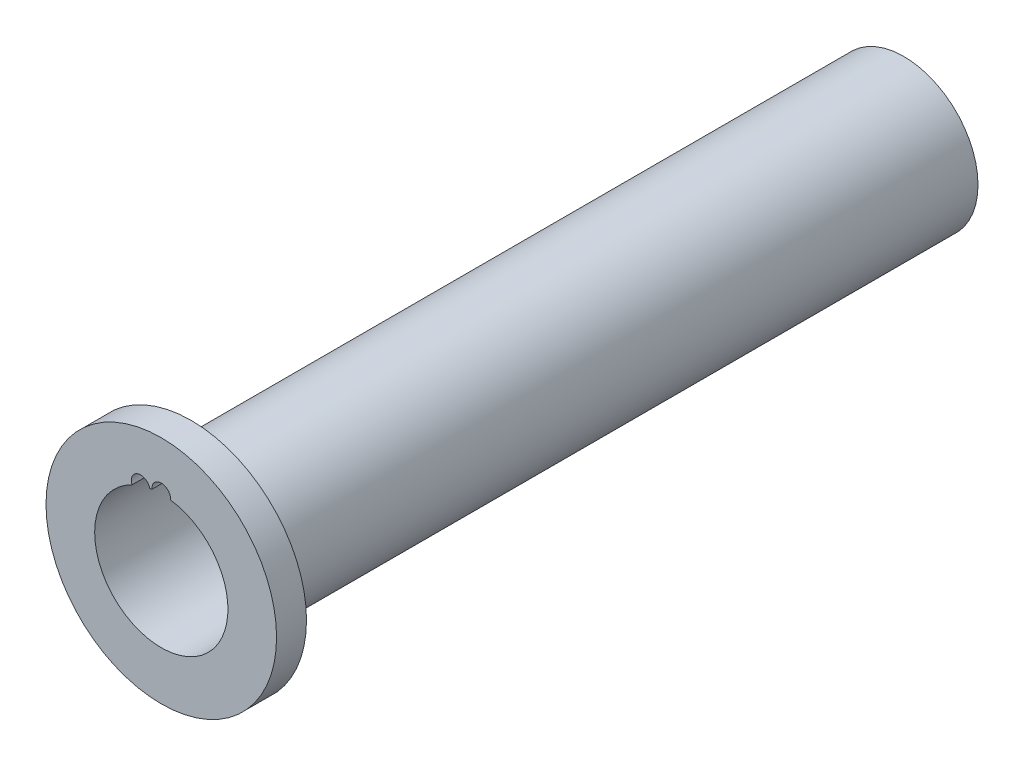
from build123d import *

# Parameters (mm, degrees)
SKETCH1_R                      = 4.95
SKETCH1_R_2                    = 4.45
BOSS_EXTRUDE1_DEPTH            = 47.6
SKETCH5_R                      = 7.7
SKETCH5_R_2                    = 4.45
BOSS_EXTRUDE3_DEPTH            = 2
SKETCH2_R                      = 0.625
CUT_EXTRUDE1_DEPTH             = 0.7
CUT_EXTRUDE1_DIRECTION_2_REACH = 4


with BuildPart() as part:
    # Sketch1 → Boss-Extrude1 (new body)
    with BuildSketch(Plane.XY):
        Circle(SKETCH1_R)
        Circle(SKETCH1_R_2, mode=Mode.SUBTRACT)
    extrude(amount=BOSS_EXTRUDE1_DEPTH)

    # Sketch5 → Boss-Extrude3 (add)
    with BuildSketch(Plane.XY.offset(47.6)):
        Circle(SKETCH5_R)
        Circle(SKETCH5_R_2, mode=Mode.SUBTRACT)
    extrude(amount=BOSS_EXTRUDE3_DEPTH)

    # Sketch2 → Cut-Extrude1 (cut)
    with BuildSketch(Plane(origin=(0, 0, 47.6), x_dir=(-1, 0, 0), z_dir=(0, 0, -1))):
        with Locations((0, 4.45)):
            Circle(SKETCH2_R)
        with Locations((1.375125625, 4.232201498)):
            Circle(SKETCH2_R)
    extrude(amount=CUT_EXTRUDE1_DEPTH, mode=Mode.SUBTRACT)

    # Sketch2 → Cut-Extrude1 direction 2 (cut, up to next)
    with BuildSketch(Plane(origin=(0, 0, 47.6), x_dir=(-1, 0, 0), z_dir=(0, 0, -1)), mode=Mode.PRIVATE) as cut_extrude1_direction_2_sk1:
        with Locations((0, 4.45)):
            Circle(SKETCH2_R)
    cut_extrude1_direction_2_tool1 = extrude(cut_extrude1_direction_2_sk1.sketch, amount=-CUT_EXTRUDE1_DIRECTION_2_REACH, mode=Mode.PRIVATE) & part.part
    add(cut_extrude1_direction_2_tool1.solids().sort_by_distance((0, 4.45, 47.6))[0], mode=Mode.SUBTRACT)
    # Sketch2 → Cut-Extrude1 direction 2 (cut, up to next)
    with BuildSketch(Plane(origin=(0, 0, 47.6), x_dir=(-1, 0, 0), z_dir=(0, 0, -1)), mode=Mode.PRIVATE) as cut_extrude1_direction_2_sk2:
        with Locations((1.375125625, 4.232201498)):
            Circle(SKETCH2_R)
    cut_extrude1_direction_2_tool2 = extrude(cut_extrude1_direction_2_sk2.sketch, amount=-CUT_EXTRUDE1_DIRECTION_2_REACH, mode=Mode.PRIVATE) & part.part
    add(cut_extrude1_direction_2_tool2.solids().sort_by_distance((-1.375126, 4.232201, 47.6))[0], mode=Mode.SUBTRACT)


solid = part.part
